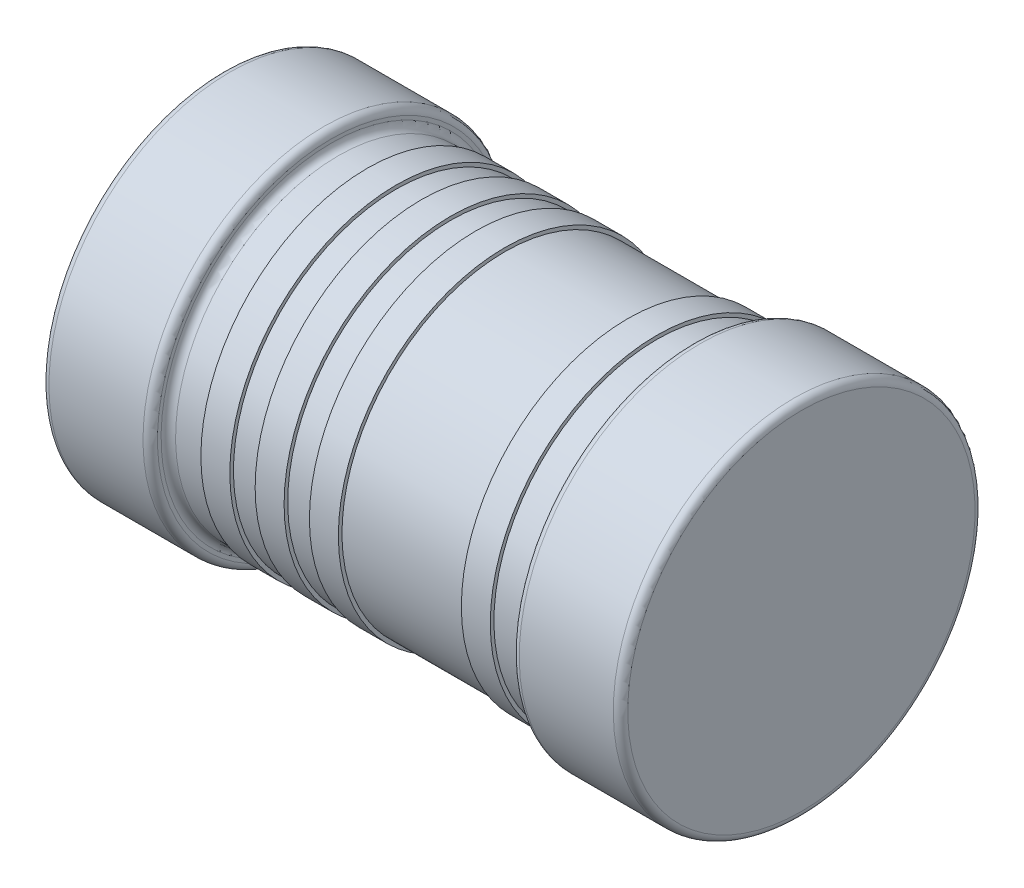
from build123d import *


with BuildPart() as part:
    # Sketch1 → Revolve1 (revolve)
    with BuildSketch(Plane.XY):
        with BuildLine():
            Line((-0.8, 0.5), (0.8, 0.5))
            Line((0.8, 0.5), (0.8, 0.02))
            ThreePointArc((0.8, 0.02), (0.794142136, 0.005857864), (0.78, 0))
            Line((0.78, 0), (0.52, 0))
            ThreePointArc((0.52, 0), (0.505857864, 0.005857864), (0.5, 0.02))
            Line((0.5, 0.02), (0.5, 0.03))
            ThreePointArc((0.5, 0.03), (0.494142136, 0.044142136), (0.48, 0.05))
            Line((0.48, 0.05), (0.4, 0.05))
            Line((0.4, 0.05), (0.4, 0.04))
            Line((0.4, 0.04), (0.32, 0.04))
            Line((0.32, 0.04), (0.32, 0.05))
            Line((0.32, 0.05), (-0.02, 0.05))
            Line((-0.02, 0.05), (-0.02, 0.04))
            Line((-0.02, 0.04), (-0.1, 0.04))
            Line((-0.1, 0.04), (-0.1, 0.05))
            Line((-0.1, 0.05), (-0.17, 0.05))
            Line((-0.17, 0.05), (-0.17, 0.04))
            Line((-0.17, 0.04), (-0.25, 0.04))
            Line((-0.25, 0.04), (-0.25, 0.05))
            Line((-0.25, 0.05), (-0.32, 0.05))
            Line((-0.32, 0.05), (-0.32, 0.04))
            Line((-0.32, 0.04), (-0.4, 0.04))
            Line((-0.4, 0.04), (-0.4, 0.05))
            Line((-0.4, 0.05), (-0.48, 0.05))
            ThreePointArc((-0.48, 0.05), (-0.494142136, 0.044142136), (-0.5, 0.03))
            Line((-0.5, 0.03), (-0.5, 0.02))
            ThreePointArc((-0.5, 0.02), (-0.505857864, 0.005857864), (-0.52, 0))
            Line((-0.52, 0), (-0.78, 0))
            ThreePointArc((-0.78, 0), (-0.794142136, 0.005857864), (-0.8, 0.02))
            Line((-0.8, 0.02), (-0.8, 0.5))
        make_face()
    revolve(axis=Axis((-0.8, 0.5, 0), (-1, 0, 0)))


solid = part.part
